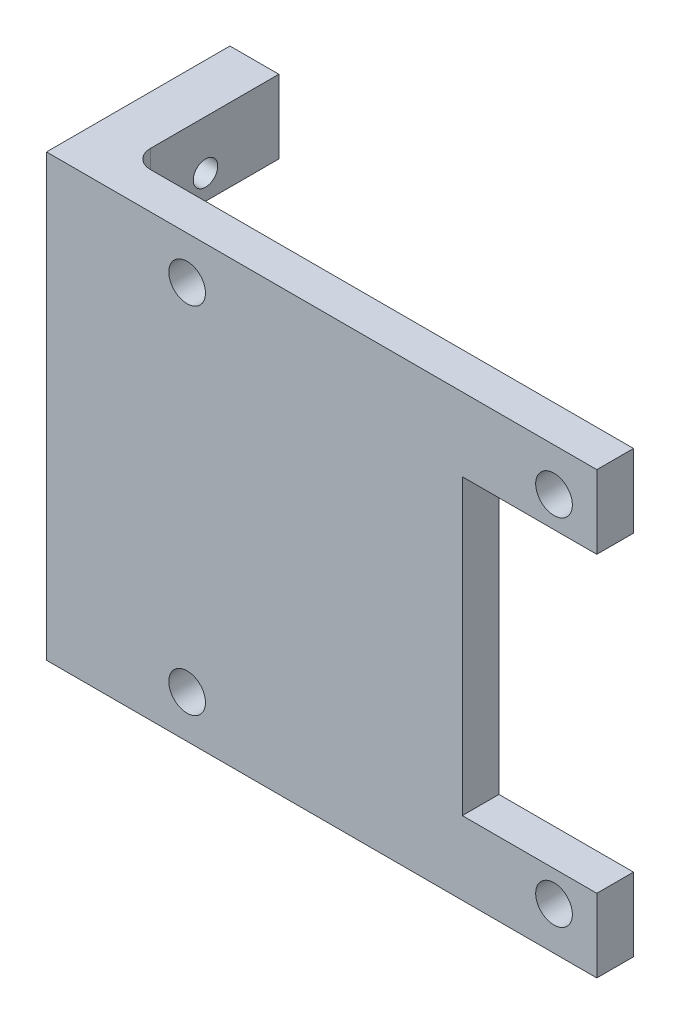
from build123d import *

# Parameters (mm, degrees)
BOSS_EXTRUDE1_DEPTH = 3
CUT_EXTRUDE1_REACH  = 5
SKETCH2_R           = 1.5
SKETCH6_W           = 3
SKETCH6_H           = 36
BOSS_EXTRUDE3_DEPTH = 8
SKETCH9_W           = 4
SKETCH9_H           = 6
BOSS_EXTRUDE4_DEPTH = 12
CUT_EXTRUDE2_REACH  = 6
SKETCH10_R          = 1
FILLET1_R           = 1.5


with BuildPart() as part:
    # Sketch1 → Boss-Extrude1 (new body)
    with BuildSketch(Plane.XY):
        Polygon((-18.5, 18), (18.5, 18), (18.5, 12), (7.5, 12), (7.5, -12), (18.5, -12), (18.5, -18), (-18.5, -18), align=None)
    extrude(amount=BOSS_EXTRUDE1_DEPTH)

    # Sketch2 → Cut-Extrude1 (cut, up to next)
    with BuildSketch(Plane.XY, mode=Mode.PRIVATE) as cut_extrude1_sk1:
        with Locations((-15, -14.5)):
            Circle(SKETCH2_R)
    cut_extrude1_tool1 = extrude(cut_extrude1_sk1.sketch, amount=CUT_EXTRUDE1_REACH, mode=Mode.PRIVATE) & part.part
    add(cut_extrude1_tool1.solids().sort_by_distance((-15, -14.5, 0))[0], mode=Mode.SUBTRACT)
    # Sketch2 → Cut-Extrude1 (cut, up to next)
    with BuildSketch(Plane.XY, mode=Mode.PRIVATE) as cut_extrude1_sk2:
        with Locations((15, -14.5)):
            Circle(SKETCH2_R)
    cut_extrude1_tool2 = extrude(cut_extrude1_sk2.sketch, amount=CUT_EXTRUDE1_REACH, mode=Mode.PRIVATE) & part.part
    add(cut_extrude1_tool2.solids().sort_by_distance((15, -14.5, 0))[0], mode=Mode.SUBTRACT)
    # Sketch2 → Cut-Extrude1 (cut, up to next)
    with BuildSketch(Plane.XY, mode=Mode.PRIVATE) as cut_extrude1_sk3:
        with Locations((15, 14.5)):
            Circle(SKETCH2_R)
    cut_extrude1_tool3 = extrude(cut_extrude1_sk3.sketch, amount=CUT_EXTRUDE1_REACH, mode=Mode.PRIVATE) & part.part
    add(cut_extrude1_tool3.solids().sort_by_distance((15, 14.5, 0))[0], mode=Mode.SUBTRACT)
    # Sketch2 → Cut-Extrude1 (cut, up to next)
    with BuildSketch(Plane.XY, mode=Mode.PRIVATE) as cut_extrude1_sk4:
        with Locations((-15, 14.5)):
            Circle(SKETCH2_R)
    cut_extrude1_tool4 = extrude(cut_extrude1_sk4.sketch, amount=CUT_EXTRUDE1_REACH, mode=Mode.PRIVATE) & part.part
    add(cut_extrude1_tool4.solids().sort_by_distance((-15, 14.5, 0))[0], mode=Mode.SUBTRACT)

    # Sketch6 → Boss-Extrude3 (add)
    with BuildSketch(Plane.ZY.offset(18.5)):
        with Locations((1.5, 0)):
            Rectangle(SKETCH6_W, SKETCH6_H)
    extrude(amount=BOSS_EXTRUDE3_DEPTH)

    # Sketch9 → Boss-Extrude4 (add)
    with BuildSketch(Plane.XY):
        with Locations((-24.5, 15)):
            Rectangle(SKETCH9_W, SKETCH9_H)
        with Locations((-24.5, -15)):
            Rectangle(SKETCH9_W, SKETCH9_H)
    extrude(amount=-BOSS_EXTRUDE4_DEPTH)

    # Sketch10 → Cut-Extrude2 (cut, up to next)
    with BuildSketch(Plane(origin=(-22.5, 0, 0), x_dir=(0, 0, -1), z_dir=(1, 0, 0)), mode=Mode.PRIVATE) as cut_extrude2_sk1:
        with Locations((6, 14)):
            Circle(SKETCH10_R)
    cut_extrude2_tool1 = extrude(cut_extrude2_sk1.sketch, amount=-CUT_EXTRUDE2_REACH, mode=Mode.PRIVATE) & part.part
    add(cut_extrude2_tool1.solids().sort_by_distance((-22.5, 14, -6))[0], mode=Mode.SUBTRACT)
    # Sketch10 → Cut-Extrude2 (cut, up to next)
    with BuildSketch(Plane(origin=(-22.5, 0, 0), x_dir=(0, 0, -1), z_dir=(1, 0, 0)), mode=Mode.PRIVATE) as cut_extrude2_sk2:
        with Locations((6, -14)):
            Circle(SKETCH10_R)
    cut_extrude2_tool2 = extrude(cut_extrude2_sk2.sketch, amount=-CUT_EXTRUDE2_REACH, mode=Mode.PRIVATE) & part.part
    add(cut_extrude2_tool2.solids().sort_by_distance((-22.5, -14, -6))[0], mode=Mode.SUBTRACT)

    # Fillet1
    fillet1_edges = [part.edges().sort_by_distance(p)[0] for p in [
        (-24.5, 12, 0),
        (-22.5, 15, 0),
        (-24.5, -12, 0),
        (-22.5, -15, 0),
    ]]
    fillet(fillet1_edges, radius=FILLET1_R)


solid = part.part
